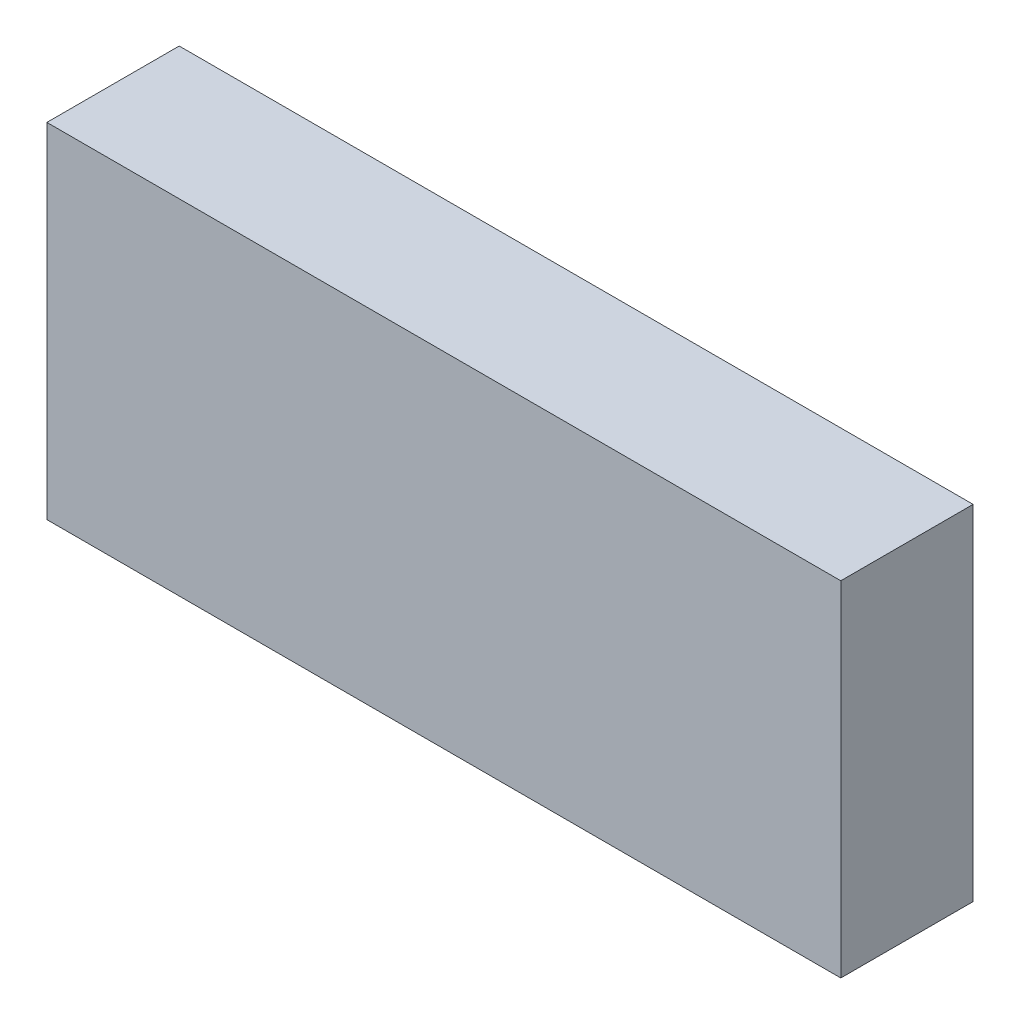
from build123d import *

# Parameters (mm, degrees)
SKETCH1_W           = 38.1
SKETCH1_H           = 16.51
BOSS_EXTRUDE1_DEPTH = 3.175


with BuildPart() as part:
    # Sketch1 → Boss-Extrude1 (new body, symmetric)
    with BuildSketch(Plane.XY):
        Rectangle(SKETCH1_W, SKETCH1_H)
    extrude(amount=BOSS_EXTRUDE1_DEPTH, both=True)


solid = part.part
